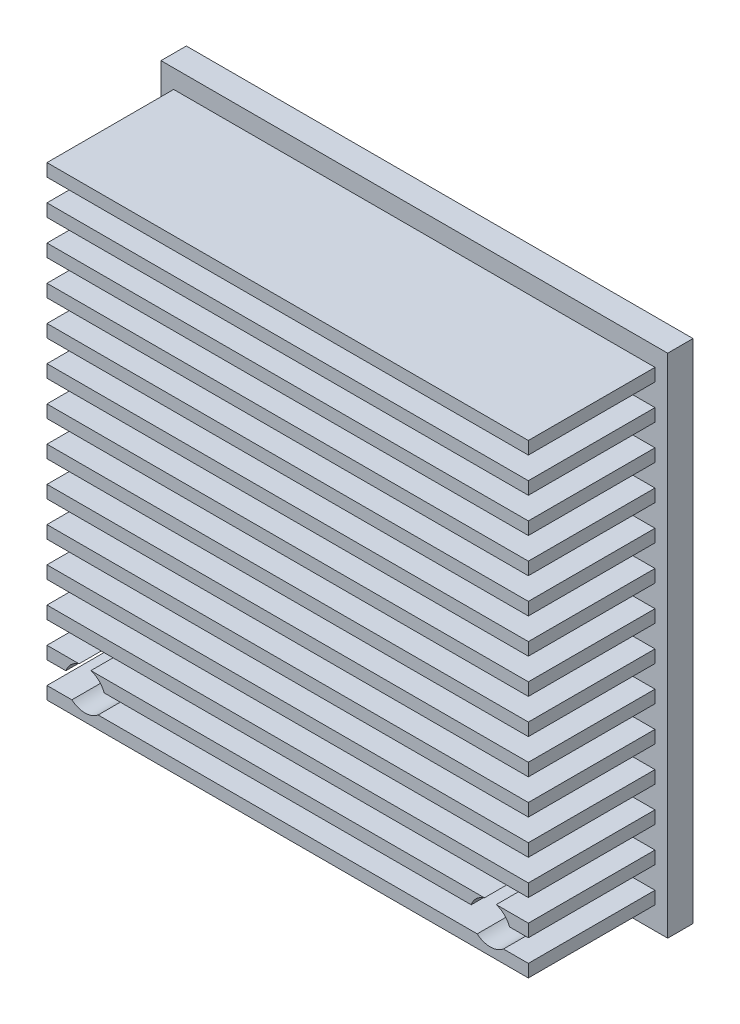
from build123d import *

# Parameters (mm, degrees)
SKETCH1_W           = 40
SKETCH1_H           = 40
BOSS_EXTRUDE1_DEPTH = 2
SKETCH2_W           = 38
SKETCH2_H           = 1
BOSS_EXTRUDE2_DEPTH = 10
SKETCH3_R           = 1.6
CUT_EXTRUDE1_DEPTH  = 13


with BuildPart() as part:
    # Sketch1 → Boss-Extrude1 (new body)
    with BuildSketch(Plane.XY):
        Rectangle(SKETCH1_W, SKETCH1_H)
    extrude(amount=BOSS_EXTRUDE1_DEPTH)

    # Sketch2 → Boss-Extrude2 (add)
    with BuildSketch(Plane.XY.offset(2)):
        with Locations((0, 15.280666702)):
            Rectangle(SKETCH2_W, SKETCH2_H)
        with Locations((0, 18.030666702)):
            Rectangle(SKETCH2_W, SKETCH2_H)
        with Locations((0, 12.530666702)):
            Rectangle(SKETCH2_W, SKETCH2_H)
        with Locations((0, 9.780666702)):
            Rectangle(SKETCH2_W, SKETCH2_H)
        with Locations((0, 7.030666702)):
            Rectangle(SKETCH2_W, SKETCH2_H)
        with Locations((0, 4.280666702)):
            Rectangle(SKETCH2_W, SKETCH2_H)
        with Locations((0, 1.530666702)):
            Rectangle(SKETCH2_W, SKETCH2_H)
        with Locations((0, -1.219333298)):
            Rectangle(SKETCH2_W, SKETCH2_H)
        with Locations((0, -3.969333298)):
            Rectangle(SKETCH2_W, SKETCH2_H)
        with Locations((0, -6.719333298)):
            Rectangle(SKETCH2_W, SKETCH2_H)
        with Locations((0, -9.469333298)):
            Rectangle(SKETCH2_W, SKETCH2_H)
        with Locations((0, -12.219333298)):
            Rectangle(SKETCH2_W, SKETCH2_H)
        with Locations((0, -14.969333298)):
            Rectangle(SKETCH2_W, SKETCH2_H)
        with Locations((0, -17.719333298)):
            Rectangle(SKETCH2_W, SKETCH2_H)
    extrude(amount=BOSS_EXTRUDE2_DEPTH)

    # Sketch3 → Cut-Extrude1 (cut, through all)
    with BuildSketch(Plane(origin=(0, 0, 0), x_dir=(-1, 0, 0), z_dir=(0, 0, -1))):
        with Locations((16, -16)):
            Circle(SKETCH3_R)
        with Locations((-16, -16)):
            Circle(SKETCH3_R)
    extrude(amount=-CUT_EXTRUDE1_DEPTH, mode=Mode.SUBTRACT)


solid = part.part
